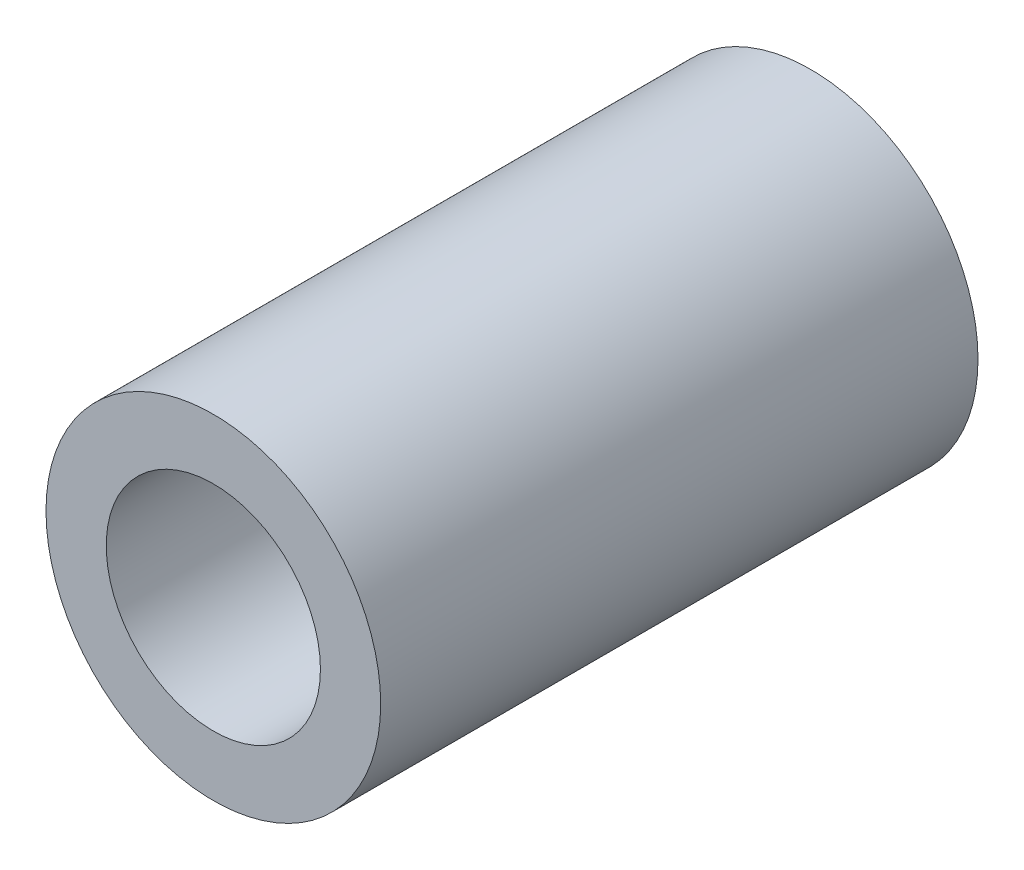
from build123d import *

# Parameters (mm, degrees)
SKETCH1_R           = 4.7625
SKETCH1_R_2         = 3.048
BOSS_EXTRUDE1_DEPTH = 17


with BuildPart() as part:
    # Sketch1 → Boss-Extrude1 (new body)
    with BuildSketch(Plane.XY):
        Circle(SKETCH1_R)
        Circle(SKETCH1_R_2, mode=Mode.SUBTRACT)
    extrude(amount=BOSS_EXTRUDE1_DEPTH)


solid = part.part
